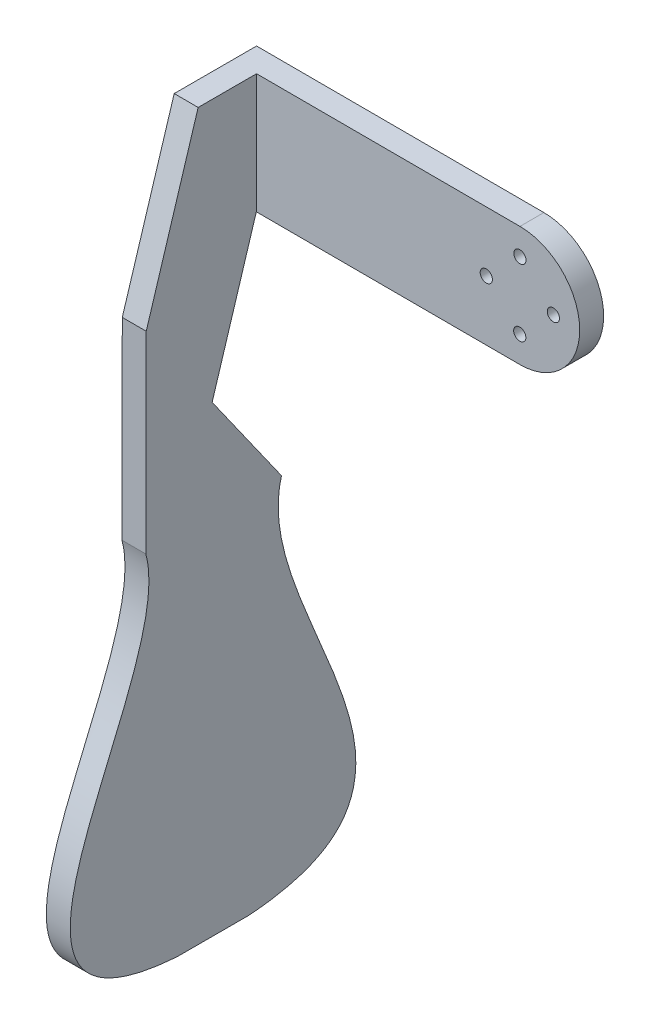
from build123d import *

# Parameters (mm, degrees)
SKETCH2_R           = 10
SKETCH2_R_2         = 1.275
BOSS_EXTRUDE1_DEPTH = 3
SKETCH3_R           = 1.275
BOSS_EXTRUDE2_DEPTH = 5
BOSS_EXTRUDE3_DEPTH = 5


with BuildPart() as part:
    # Sketch2 → Boss-Extrude1 (new body)
    with BuildSketch(Plane.XY):
        Circle(SKETCH2_R)
        with Locations((6.999985487, -0.014254341)):
            Circle(SKETCH2_R_2, mode=Mode.SUBTRACT)
        with Locations((-0.014254341, -6.999985487)):
            Circle(SKETCH2_R_2, mode=Mode.SUBTRACT)
        with Locations((-6.999985487, 0.014254341)):
            Circle(SKETCH2_R_2, mode=Mode.SUBTRACT)
        with Locations((0.014254341, 6.999985487)):
            Circle(SKETCH2_R_2, mode=Mode.SUBTRACT)
    extrude(amount=BOSS_EXTRUDE1_DEPTH)

    # Sketch3 → Boss-Extrude2 (add)
    with BuildSketch(Plane.XY.offset(3)):
        with BuildLine():
            Line((-0.02545418, -12.499974083), (-60.02532978, -12.377794019))
            Line((-60.02532978, -12.377794019), (-59.97442142, 12.622154148))
            Line((-59.97442142, 12.622154148), (0.02545418, 12.499974083))
            ThreePointArc((0.02545418, 12.499974083), (12.499974083, -0.02545418), (-0.02545418, -12.499974083))
        make_face()
        with Locations((6.999985487, -0.014254341)):
            Circle(SKETCH3_R, mode=Mode.SUBTRACT)
        with Locations((-0.014254341, -6.999985487)):
            Circle(SKETCH3_R, mode=Mode.SUBTRACT)
        with Locations((-6.999985487, 0.014254341)):
            Circle(SKETCH3_R, mode=Mode.SUBTRACT)
        with Locations((0.014254341, 6.999985487)):
            Circle(SKETCH3_R, mode=Mode.SUBTRACT)
    extrude(amount=-BOSS_EXTRUDE2_DEPTH)

    # Sketch4 → Boss-Extrude3 (add)
    with BuildSketch(Plane(origin=(-59.9998756, 0.122180064, 0), x_dir=(0.002036334, 0.999997927, 0), z_dir=(-0.999997927, 0.002036334, 0))):
        with BuildLine():
            Line((-62.942627893, -25.970573692), (-22.627671819, -25.970573692))
            Line((-22.627671819, -25.970573692), (12.5, -15.199288929))
            Line((12.5, -15.199288929), (12.5, -3))
            Line((12.5, -3), (-12.5, -3))
            Line((-12.5, -3), (-42.396291449, -12.167173681))
            Line((-42.396291449, -12.167173681), (-62.942627893, 2.349426308))
            add(Edge.make_bspline(
                [(-62.942627893, 2.349426308), (-87.492278411, -4.509248518), (-135.602543773, 45.42627104), (-139.208088658, -4.310573692)],
                knots=[0, 0, 0, 0, 1, 1, 1, 1], degree=3))
            Line((-139.208088658, -4.310573692), (-139.208088658, -19.310573692))
            add(Edge.make_bspline(
                [(-62.942627893, -25.970573692), (-87.492278411, -19.111898866), (-135.602543773, -69.047418424), (-139.208088658, -19.310573692)],
                knots=[0, 0, 0, 0, 1, 1, 1, 1], degree=3))
        make_face()
    extrude(amount=-BOSS_EXTRUDE3_DEPTH)


solid = part.part
